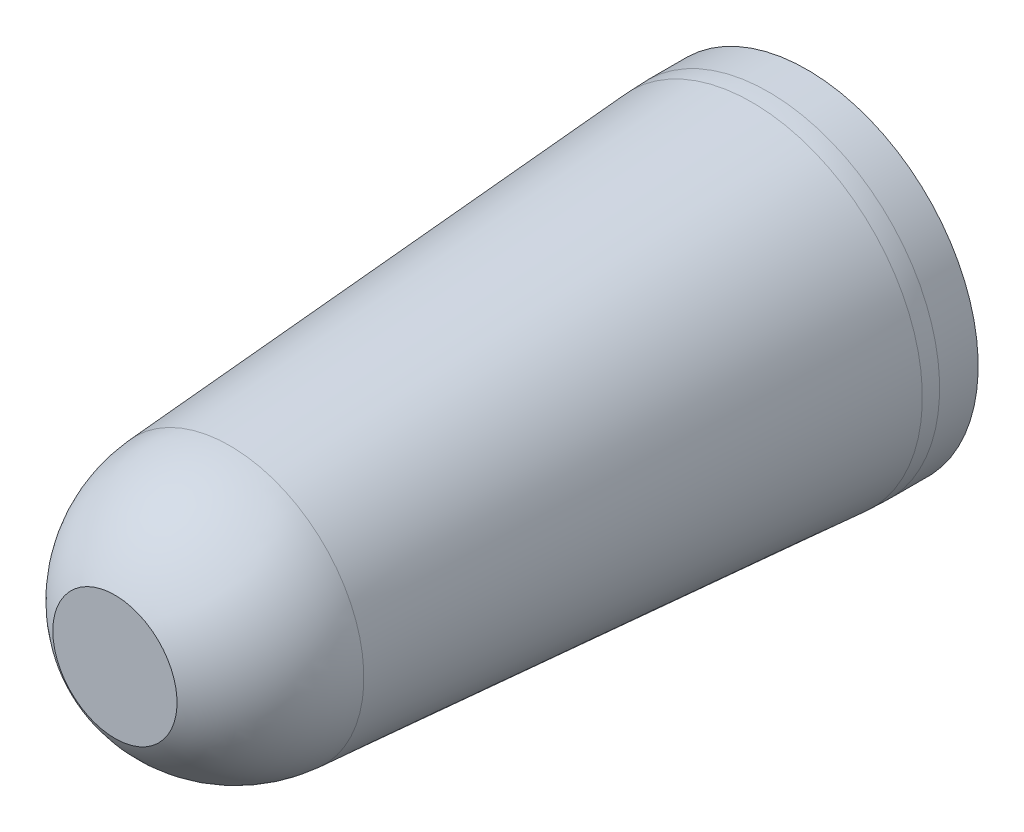
from build123d import *


with BuildPart() as part:
    # Sketch1 → Revolve1 (revolve)
    with BuildSketch(Plane(origin=(0, 0, 0), x_dir=(0, 0, -1), z_dir=(1, 0, 0))):
        with BuildLine():
            Line((0, 49.747863485), (-12.878101339, 49.747863485))
            ThreePointArc((-12.878101339, 49.747863485), (-15.666918513, 49.6991845), (-18.452337943, 49.553206853))
            Line((-18.452337943, 49.553206853), (-192.854569693, 37.357814791))
            ThreePointArc((-192.854569693, 37.357814791), (-215.057218111, 30.143737011), (-231.274188718, 13.35057235))
            Line((-231.274188718, 13.35057235), (-231.274188718, -7.402136515))
            Line((-231.274188718, -7.402136515), (0, -7.402136515))
            Line((0, -7.402136515), (0, 49.747863485))
        make_face()
    revolve(axis=Axis((0, -7.402136515, 0), (0, 0, 1)))


solid = part.part
